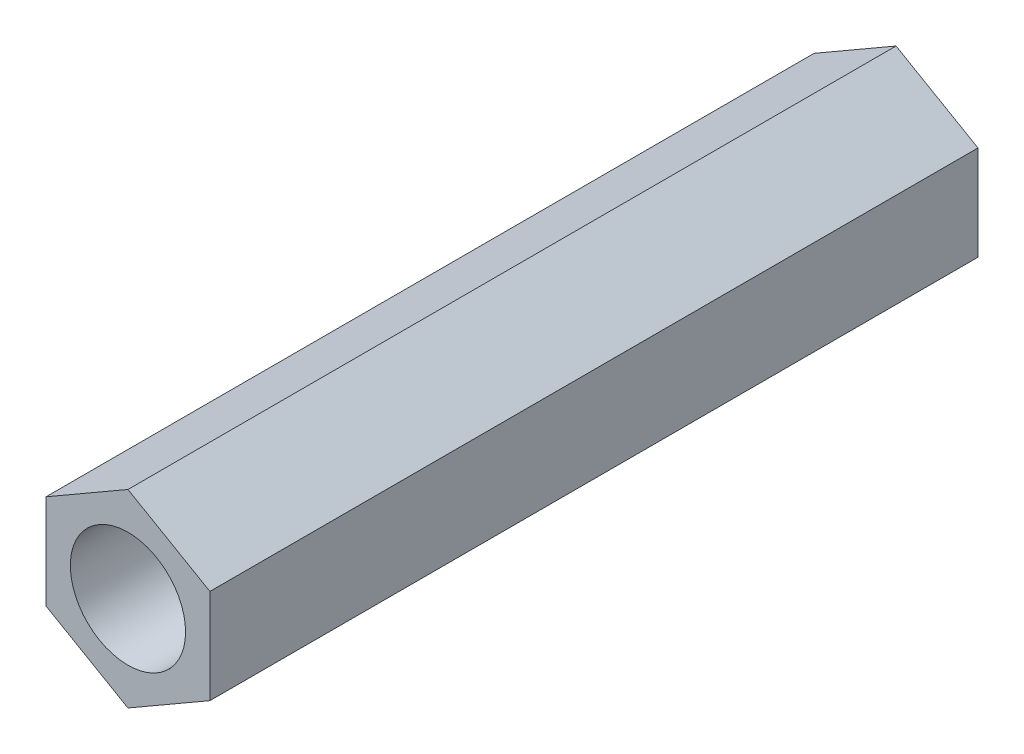
from build123d import *

# Parameters (mm, degrees)
SKETCH_1_R      = 1.5
EXTRUDE_1_DEPTH = 20


with BuildPart() as part:
    # 草图1 → 凸台-拉伸1 (new body)
    with BuildSketch(Plane.XY):
        Polygon((0, 2.463929225), (-2.133825302, 1.231964612), (-2.133825302, -1.231964612), (0, -2.463929225), (2.133825302, -1.231964612), (2.133825302, 1.231964612), align=None)
        Circle(SKETCH_1_R, mode=Mode.SUBTRACT)
    extrude(amount=EXTRUDE_1_DEPTH)


solid = part.part
